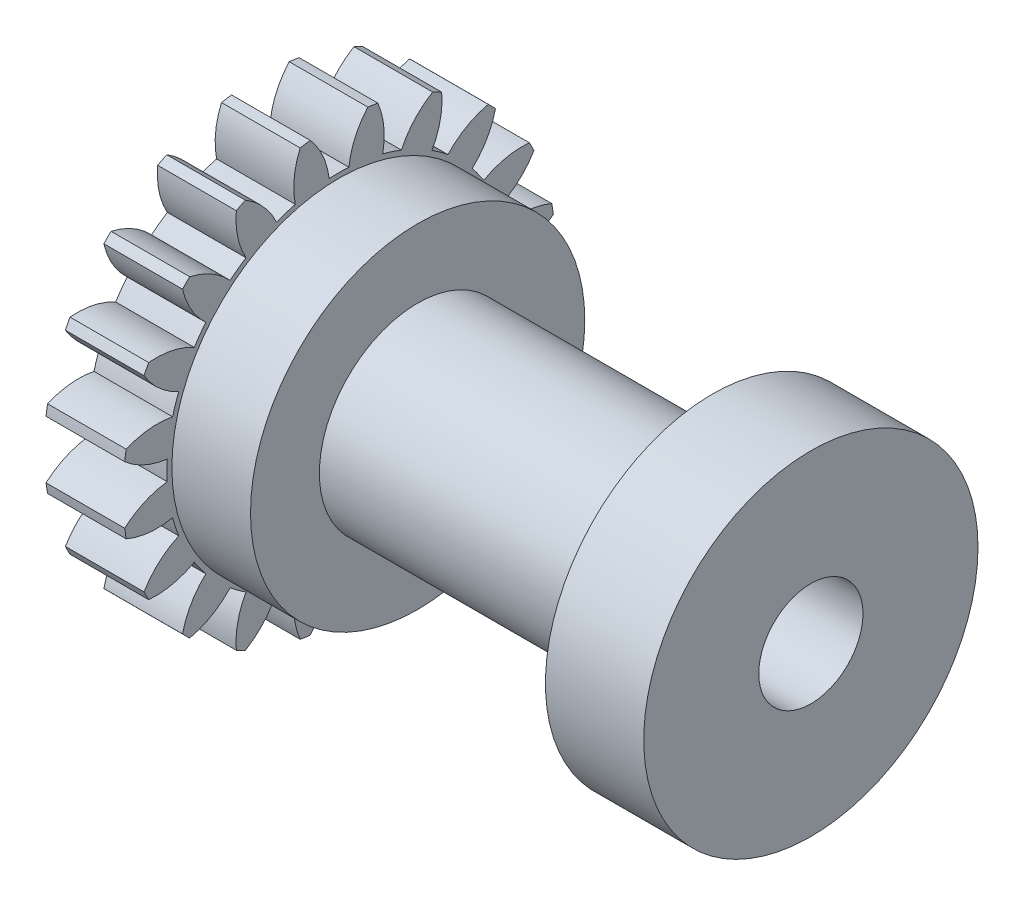
from build123d import *

# Parameters (mm, degrees)
BASPROSKE_W             = 4
BASPROSKE_H             = 11
TOOTHCUT_DEPTH          = 17.062378404
TEETHCUTS_COUNT         = 20
TEETHCUTS_ANGLE         = 342
BORSKE_R                = 2.5
BORE_DEPTH              = 50.0000508
SKETCH1_R               = 8.5
BOSS_EXTRUDE1_DEPTH     = 4
SKETCH2_R               = 5
BOSS_EXTRUDE2_DEPTH     = 15
SKETCH3_R               = 8.5
BOSS_EXTRUDE3_DEPTH     = 5
SKETCH4_R               = 2.65
CUT_EXTRUDE1_DEPTH      = 32.964164392
CUT_EXTRUDE1_DEPTH_BACK = 32.964164392


with BuildPart() as part:
    # BasProSke → Base-Revolve (revolve)
    with BuildSketch(Plane(origin=(0, 0, 0), x_dir=(1, 0, 0), z_dir=(0, 1, 0)), mode=Mode.PRIVATE) as base_revolve_sk:
        with Locations((2, 5.5)):
            Rectangle(BASPROSKE_W, BASPROSKE_H)
    revolve(base_revolve_sk.sketch.rotate(Axis((-10, 0, 0), (1, 0, 0)), 180), axis=Axis((-10, 0, 0), (1, 0, 0)))

    # TooCutSke → ToothCut (cut, through all)
    with BuildSketch(Plane(origin=(0, 0, 0), x_dir=(0, 0, -1), z_dir=(1, 0, 0))):
        with BuildLine():
            ThreePointArc((0.499924007, 8.734705318), (0, 8.749), (-0.499924007, 8.734705318))
            ThreePointArc((-0.499924007, 8.734705318), (-0.824302243, 9.905497836), (-1.485192705, 10.924909509))
            ThreePointArc((-1.485192705, 10.924909509), (0, 11.0254), (1.485192705, 10.924909509))
            ThreePointArc((1.485192705, 10.924909509), (0.824302243, 9.905497836), (0.499924007, 8.734705318))
        make_face()
    toothcut = extrude(amount=TOOTHCUT_DEPTH, mode=Mode.SUBTRACT)

    # TeethCuts: ToothCut ×20 about axis
    teethcuts_axis = Axis((-10, 0, 0), (1, 0, 0))
    for i in range(1, TEETHCUTS_COUNT):
        add(toothcut.rotate(teethcuts_axis, i * TEETHCUTS_ANGLE / (TEETHCUTS_COUNT - 1)), mode=Mode.SUBTRACT)

    # BorSke → Bore (cut, symmetric)
    with BuildSketch(Plane(origin=(0, 0, 0), x_dir=(0, 0, -1), z_dir=(1, 0, 0))):
        with Locations(Location((0, 0, 0), (0, 0, 180))):
            Circle(BORSKE_R)
    extrude(amount=BORE_DEPTH, both=True, mode=Mode.SUBTRACT)

    # Sketch1 → Boss-Extrude1 (add)
    with BuildSketch(Plane(origin=(4, 0, 0), x_dir=(0, 0, -1), z_dir=(1, 0, 0))):
        with Locations(Location((0, 0, 0), (0, 0, 180))):
            Circle(SKETCH1_R)
    extrude(amount=BOSS_EXTRUDE1_DEPTH)

    # Sketch2 → Boss-Extrude2 (add)
    with BuildSketch(Plane(origin=(8, 0, 0), x_dir=(0, 0, -1), z_dir=(1, 0, 0))):
        Circle(SKETCH2_R)
    extrude(amount=BOSS_EXTRUDE2_DEPTH)

    # Sketch3 → Boss-Extrude3 (add)
    with BuildSketch(Plane(origin=(23, 0, 0), x_dir=(0, 0, -1), z_dir=(1, 0, 0))):
        with Locations(Location((0, 0, 0), (0, 0, 180))):
            Circle(SKETCH3_R)
    extrude(amount=BOSS_EXTRUDE3_DEPTH)

    # Sketch4 → Cut-Extrude1 (cut, two sides)
    with BuildSketch(Plane(origin=(28, 0, 0), x_dir=(0, 0, -1), z_dir=(1, 0, 0))) as cut_extrude1_sk:
        with Locations(Location((0, 0, 0), (0, 0, 180))):
            Circle(SKETCH4_R)
    extrude(amount=CUT_EXTRUDE1_DEPTH, mode=Mode.SUBTRACT)
    extrude(cut_extrude1_sk.sketch, amount=-CUT_EXTRUDE1_DEPTH_BACK, mode=Mode.SUBTRACT)


solid = part.part
